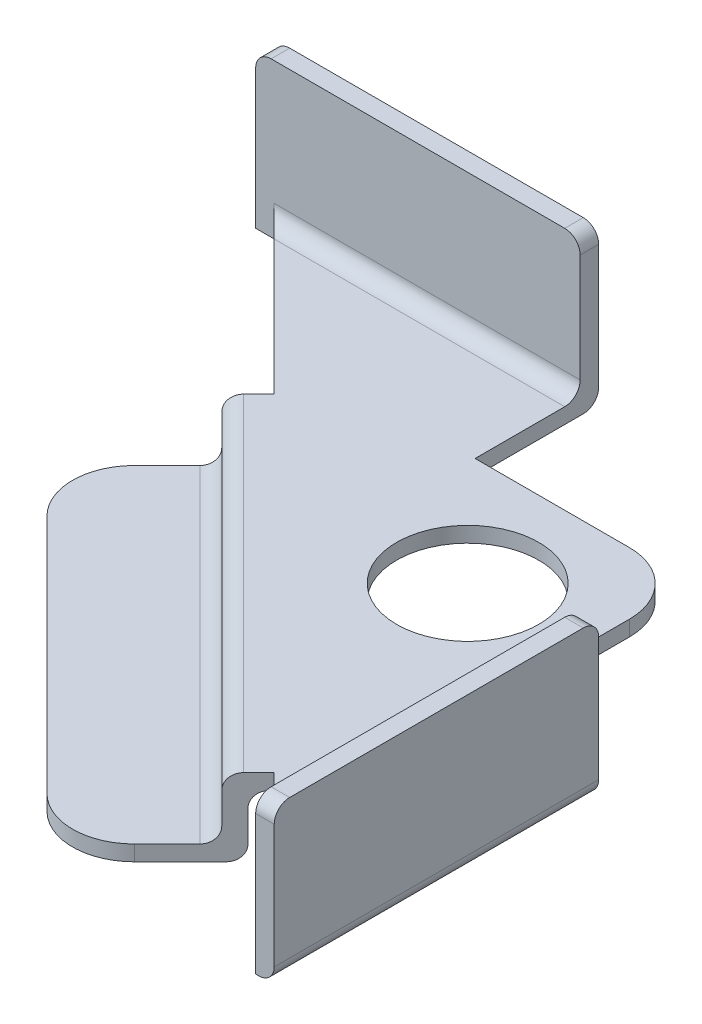
from build123d import *

# Parameters (mm, degrees)
SKETCH1_W                = 21.5
SKETCH1_H                = 21.5
BOSS_EXTRUDE1_DEPTH      = 0.5
SKETCH2_R                = 2.3
SKETCH2_W                = 4
SKETCH2_H                = 4
SKETCH2_H_2              = 7
SKETCH2_W_2              = 7
CUT_EXTRUDE1_DEPTH       = 1.5
FILLET1_R                = 2
SKETCH3_W                = 0.6
SKETCH3_H                = 10.5
SKETCH3_W_2              = 10.5
SKETCH3_H_2              = 0.6
BOSS_EXTRUDE2_DEPTH      = 4.5
BOSS_EXTRUDE2_DEPTH_BACK = 0.5
FILLET11_R               = 0.5
SKETCH6_W                = 15
SKETCH6_H                = 0.5
BOSS_EXTRUDE3_DEPTH      = 1.2
BOSS_EXTRUDE4_DEPTH      = 2
SKETCH9_W                = 15
SKETCH9_H                = 0.5
BOSS_EXTRUDE5_DEPTH      = 4
FILLET12_R               = 0.5
FILLET13_R               = 2


with BuildPart() as part:
    # Sketch1 → Boss-Extrude1 (new body)
    with BuildSketch(Plane(origin=(0, 0, 0), x_dir=(1, 0, 0), z_dir=(0, 1, 0))):
        with Locations((10.75, 10.75)):
            Rectangle(SKETCH1_W, SKETCH1_H)
    extrude(amount=BOSS_EXTRUDE1_DEPTH)

    # Sketch2 → Cut-Extrude1 (cut, through all)
    with BuildSketch(Plane(origin=(0, 0.5, 0), x_dir=(1, 0, 0), z_dir=(0, 1, 0))):
        Polygon((0, 21.5), (21.5, 0), (0, 0), align=None)
        with Locations((13.88, 13.88)):
            Circle(SKETCH2_R)
        with Locations((19.5, 19.5)):
            Rectangle(SKETCH2_W, SKETCH2_H)
        with Locations((19.5, 14)):
            Rectangle(SKETCH2_W, SKETCH2_H_2)
        with Locations((14, 19.5)):
            Rectangle(SKETCH2_W_2, SKETCH2_H)
    extrude(amount=-CUT_EXTRUDE1_DEPTH, mode=Mode.SUBTRACT)

    # Fillet1
    fillet1_edges = [part.edges().sort_by_distance(p)[0] for p in [
        (17.5, 0.25, -17.5),
    ]]
    fillet(fillet1_edges, radius=FILLET1_R)

    # Sketch3 → Boss-Extrude2 (add, two sides)
    with BuildSketch(Plane(origin=(0, 0.5, 0), x_dir=(1, 0, 0), z_dir=(0, 1, 0))) as boss_extrude2_sk:
        with Locations((21.2, 5.25)):
            Rectangle(SKETCH3_W, SKETCH3_H)
        with Locations((5.25, 21.2)):
            Rectangle(SKETCH3_W_2, SKETCH3_H_2)
    extrude(amount=BOSS_EXTRUDE2_DEPTH)
    extrude(boss_extrude2_sk.sketch, amount=-BOSS_EXTRUDE2_DEPTH_BACK)

    # Fillet11
    fillet11_edges = [part.edges().sort_by_distance(p)[0] for p in [
        (5.25, 0, -21.5),
        (21.5, 0, -5.25),
        (20.9, 0.5, -5.55),
        (21.2, 5, -10.5),
        (21.2, 5, 0),
        (5.55, 0.5, -20.9),
        (10.5, 5, -21.2),
        (0, 5, -21.2),
    ]]
    fillet(fillet11_edges, radius=FILLET11_R)

    # Sketch6 → Boss-Extrude3 (add)
    with BuildSketch(Plane(origin=(10.75, 0, -10.75), x_dir=(0.707106781, 0, 0.707106781), z_dir=(-0.707106781, 0, 0.707106781))):
        with Locations((0, 0.25)):
            Rectangle(SKETCH6_W, SKETCH6_H)
    extrude(amount=BOSS_EXTRUDE3_DEPTH)

    # Sketch8 → Boss-Extrude4 (add)
    with BuildSketch(Plane.XZ):
        Polygon((4.598171004, -15.204772721), (15.204772721, -4.598171004), (15.62903679, -5.022435072), (5.022435072, -15.62903679), align=None)
    extrude(amount=BOSS_EXTRUDE4_DEPTH)

    # Sketch9 → Boss-Extrude5 (add)
    with BuildSketch(Plane(origin=(9.901471863, 0, -9.901471863), x_dir=(0.707106781, 0, 0.707106781), z_dir=(-0.707106781, 0, 0.707106781))):
        with Locations((0, -1.75)):
            Rectangle(SKETCH9_W, SKETCH9_H)
    extrude(amount=BOSS_EXTRUDE5_DEPTH)

    # Fillet12
    fillet12_edges = [part.edges().sort_by_distance(p)[0] for p in [
        (9.901471863, 0.5, -9.901471863),
        (10.325735931, 0, -10.325735931),
        (10.325735931, -2, -10.325735931),
        (9.901471863, -1.5, -9.901471863),
    ]]
    fillet(fillet12_edges, radius=FILLET12_R)

    # Fillet13
    fillet13_edges = [part.edges().sort_by_distance(p)[0] for p in [
        (1.769743879, -1.75, -12.376345597),
        (12.376345597, -1.75, -1.769743879),
    ]]
    fillet(fillet13_edges, radius=FILLET13_R)


solid = part.part
